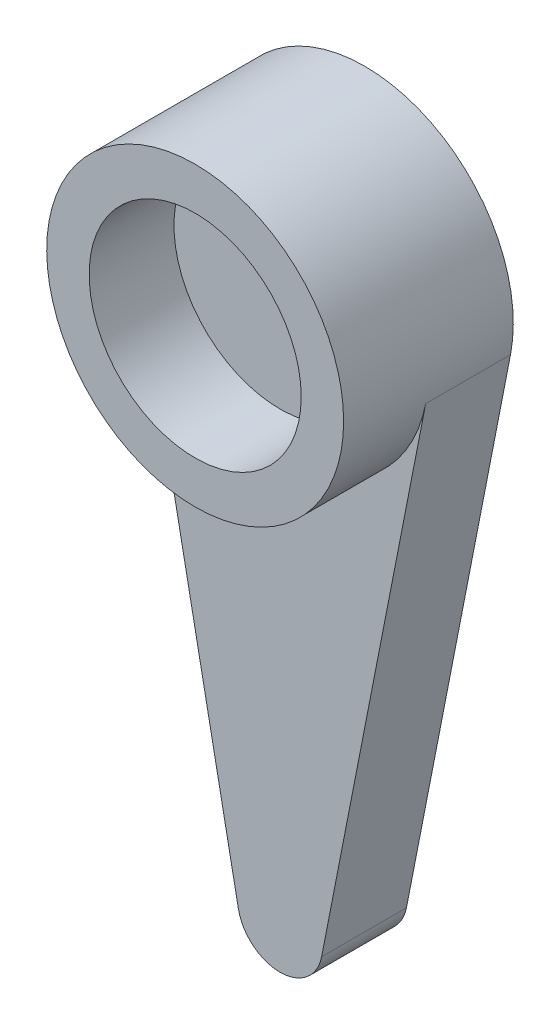
from build123d import *

# Parameters (mm, degrees)
BOSS_EXTRUDE1_DEPTH = 2
SKETCH2_R           = 3.5
SKETCH2_R_2         = 2.5
BOSS_EXTRUDE2_DEPTH = 2


with BuildPart() as part:
    # Sketch1 → Boss-Extrude1 (new body)
    with BuildSketch(Plane.XY):
        with BuildLine():
            Line((-0.981334679, -13.192307692), (-3.434671375, -0.673076923))
            ThreePointArc((-3.434671375, -0.673076923), (0, 3.5), (3.434671375, -0.673076923))
            Line((3.434671375, -0.673076923), (0.981334679, -13.192307692))
            ThreePointArc((0.981334679, -13.192307692), (0, -14), (-0.981334679, -13.192307692))
        make_face()
    extrude(amount=BOSS_EXTRUDE1_DEPTH)

    # Sketch2 → Boss-Extrude2 (add)
    with BuildSketch(Plane.XY.offset(2)):
        Circle(SKETCH2_R)
        Circle(SKETCH2_R_2, mode=Mode.SUBTRACT)
    extrude(amount=BOSS_EXTRUDE2_DEPTH)


solid = part.part
